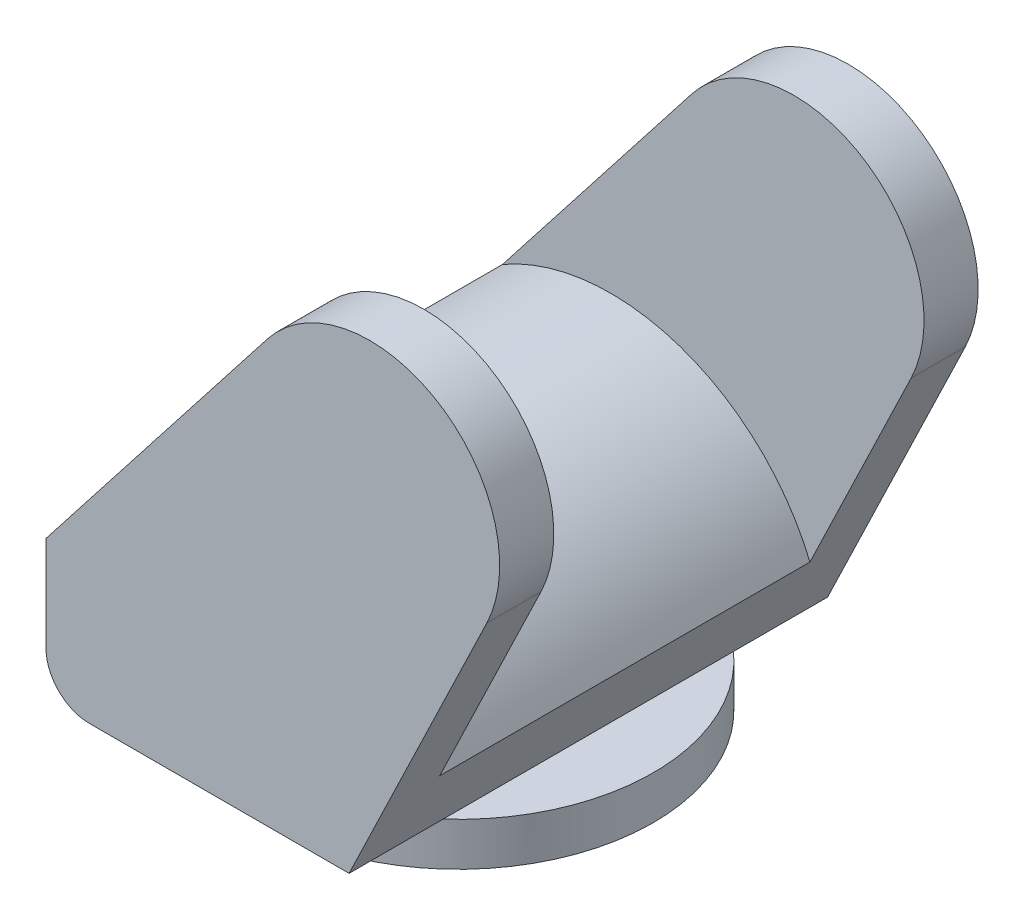
from build123d import *

# Parameters (mm, degrees)
BOSS_EXTRUDE1_DEPTH      = 110.5
BOSS_EXTRUDE1_DEPTH_BACK = 110.5
CUT_EXTRUDE1_DEPTH       = 85.5
CUT_EXTRUDE1_DEPTH_BACK  = 85.5
SKETCH3_R                = 90
BOSS_EXTRUDE2_DEPTH      = 20
BODY_MOVE_COPY1_ANGLE    = 90


with BuildPart() as part:
    # Sketch1 → Boss-Extrude1 (new, two sides: drawn at the far end of the back side and taken through both)
    with BuildSketch(Plane(origin=(0, 0, 0), x_dir=(0, 0, -1), z_dir=(1, 0, 0)).offset(-BOSS_EXTRUDE1_DEPTH_BACK)):
        with BuildLine():
            Line((-64.292863754, -51.10932545), (55.707136246, -51.10932545))
            ThreePointArc((55.707136246, -51.10932545), (69.84927187, -45.251461074), (75.707136246, -31.10932545))
            Line((75.707136246, -31.10932545), (75.707136246, 12.89067455))
            Line((75.707136246, 12.89067455), (-26.557571018, 143.789344322))
            ThreePointArc((-26.557571018, 143.789344322), (-105.517875867, 157.806043193), (-127.885671837, 80.793840961))
            Line((-127.885671837, 80.793840961), (-64.292863754, -51.10932545))
        make_face()
    extrude(amount=BOSS_EXTRUDE1_DEPTH + BOSS_EXTRUDE1_DEPTH_BACK)

    # Sketch2 → Cut-Extrude1 (cut, two sides: drawn at the far end of the back side and taken through both)
    with BuildSketch(Plane(origin=(0, 0, 0), x_dir=(0, 0, -1), z_dir=(1, 0, 0)).offset(-CUT_EXTRUDE1_DEPTH_BACK)):
        with BuildLine():
            Line((-127.885671837, 80.793840961), (-81.149808611, -16.144925076))
            ThreePointArc((-81.149808611, -16.144925076), (-21.055510127, 40.123069763), (60.857619094, 31.898033921))
            Line((60.857619094, 31.898033921), (-26.557571018, 143.789344322))
            ThreePointArc((-26.557571018, 143.789344322), (-105.517875867, 157.806043193), (-127.885671837, 80.793840961))
        make_face()
    extrude(amount=CUT_EXTRUDE1_DEPTH + CUT_EXTRUDE1_DEPTH_BACK, mode=Mode.SUBTRACT)

    # Sketch3 → Boss-Extrude2 (add)
    with BuildSketch(Plane.XZ.offset(51.10932545)):
        with Locations((0, 4.292863754)):
            Circle(SKETCH3_R)
    extrude(amount=BOSS_EXTRUDE2_DEPTH)


with BuildPart() as part_1:
    # Body-Move_Copy1: moved
    add(part.part.rotate(Axis((0, 0, 0), (0, 1, 0)), BODY_MOVE_COPY1_ANGLE))


solid = part_1.part
